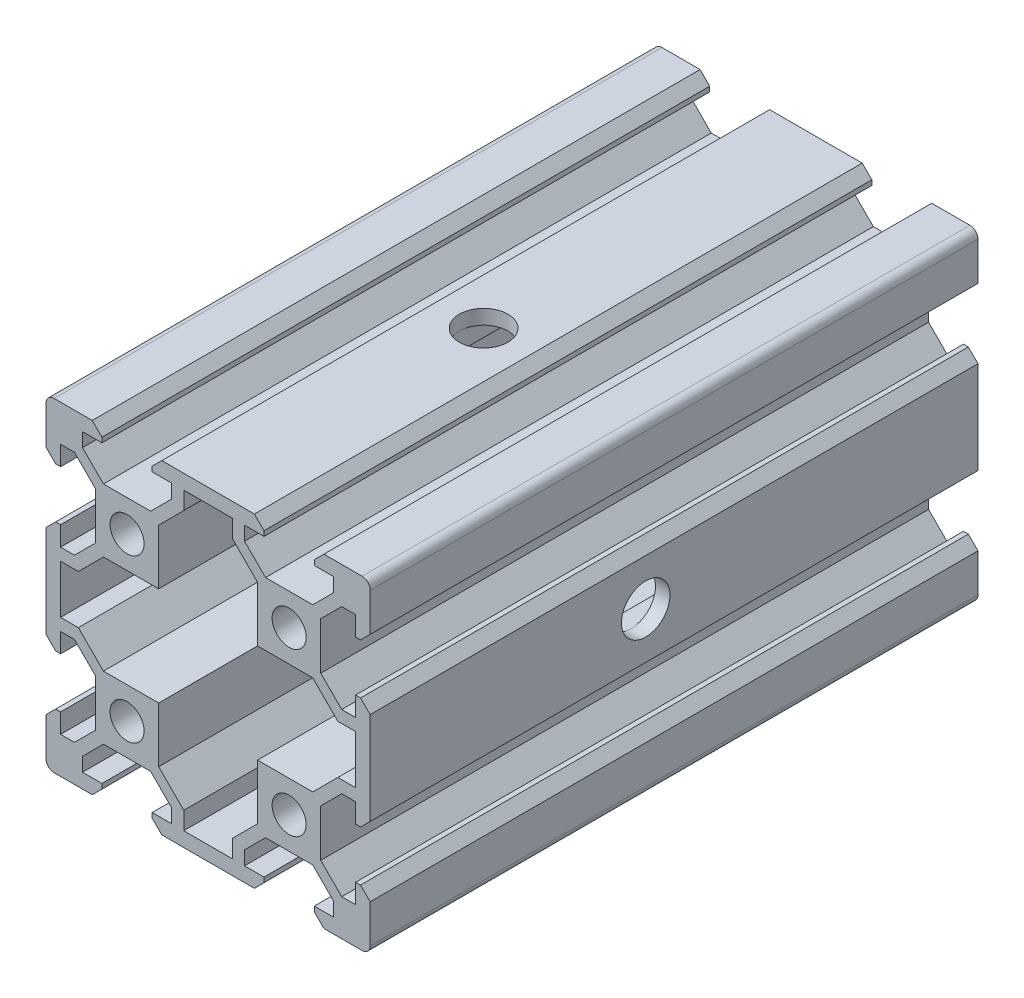
from build123d import *

# Parameters (mm, degrees)
SKETCH_1_R         = 2.1
EXTRUDE_1_DEPTH    = 75
VERRUNDUNG1_R      = 1
SKETCH1_R          = 3
CUT_EXTRUDE1_DEPTH = 41


with BuildPart() as part:
    # 草图1 → 凸台-拉伸1 (new body)
    with BuildSketch(Plane.XY):
        Polygon((5.71, 20), (-5.71, 20), (-6.9, 18.81), (-6.9, 18.2), (-4.5, 18.2), (-4.5, 16.489949494), (-7.089949494, 13.9), (-12.910050506, 13.9), (-15.5, 16.489949494), (-15.5, 18.2), (-13.1, 18.2), (-13.1, 18.81), (-14.29, 20), (-20, 20), (-20, 14.29), (-18.81, 13.1), (-18.2, 13.1), (-18.2, 15.5), (-16.489949494, 15.5), (-13.9, 12.910050506), (-13.9, 7.089949494), (-16.489949494, 4.5), (-18.2, 4.5), (-18.2, 6.9), (-18.81, 6.9), (-20, 5.71), (-20, -5.71), (-18.81, -6.9), (-18.2, -6.9), (-18.2, -4.5), (-16.489949494, -4.5), (-13.9, -7.089949494), (-13.9, -12.910050506), (-16.489949494, -15.5), (-18.2, -15.5), (-18.2, -13.1), (-18.81, -13.1), (-20, -14.29), (-20, -20), (-14.29, -20), (-13.1, -18.81), (-13.1, -18.2), (-15.5, -18.2), (-15.5, -16.489949494), (-12.910050506, -13.9), (-7.089949494, -13.9), (-4.5, -16.489949494), (-4.5, -18.2), (-6.9, -18.2), (-6.9, -18.81), (-5.71, -20), (5.71, -20), (6.9, -18.81), (6.9, -18.2), (4.5, -18.2), (4.5, -16.489949494), (7.089949494, -13.9), (12.910050506, -13.9), (15.5, -16.489949494), (15.5, -18.2), (13.1, -18.2), (13.1, -18.81), (14.29, -20), (20, -20), (20, -14.29), (18.81, -13.1), (18.2, -13.1), (18.2, -15.5), (16.489949494, -15.5), (13.9, -12.910050506), (13.9, -7.089949494), (16.489949494, -4.5), (18.2, -4.5), (18.2, -6.9), (18.81, -6.9), (20, -5.71), (20, 5.71), (18.81, 6.9), (18.2, 6.9), (18.2, 4.5), (16.489949494, 4.5), (13.9, 7.089949494), (13.9, 12.910050506), (16.489949494, 15.5), (18.2, 15.5), (18.2, 13.1), (18.81, 13.1), (20, 14.29), (20, 20), (14.29, 20), (13.1, 18.81), (13.1, 18.2), (15.5, 18.2), (15.5, 16.489949494), (12.910050506, 13.9), (7.089949494, 13.9), (4.5, 16.489949494), (4.5, 18.2), (6.9, 18.2), (6.9, 18.81), align=None)
        with Locations((-10, 10)):
            Circle(SKETCH_1_R, mode=Mode.SUBTRACT)
        with Locations((-10, -10)):
            Circle(SKETCH_1_R, mode=Mode.SUBTRACT)
        with Locations((10, -10)):
            Circle(SKETCH_1_R, mode=Mode.SUBTRACT)
        with Locations((10, 10)):
            Circle(SKETCH_1_R, mode=Mode.SUBTRACT)
        Polygon((-6.1, 6.1), (-6.1, 12.910050506), (-3, 16.010050506), (-3, 18.2), (3, 18.2), (3, 16.010050506), (6.1, 12.910050506), (6.1, 6.1), (12.910050506, 6.1), (16.010050506, 3), (18.2, 3), (18.2, -3), (16.010050506, -3), (12.910050506, -6.1), (6.1, -6.1), (6.1, -12.910050506), (3, -16.010050506), (3, -18.2), (-3, -18.2), (-3, -16.010050506), (-6.1, -12.910050506), (-6.1, -6.1), (-12.910050506, -6.1), (-16.010050506, -3), (-18.2, -3), (-18.2, 3), (-16.010050506, 3), (-12.910050506, 6.1), align=None, mode=Mode.SUBTRACT)
    extrude(amount=EXTRUDE_1_DEPTH)

    # Verrundung1
    verrundung1_edges = [part.edges().sort_by_distance(p)[0] for p in [
        (20, 20, 37.5),
        (20, -20, 37.5),
        (-20, -20, 37.5),
        (-20, 20, 37.5),
    ]]
    fillet(verrundung1_edges, radius=VERRUNDUNG1_R)

    # Sketch1 → Cut-Extrude1 (cut, through all)
    with BuildSketch(Plane.ZY.offset(20)):
        with Locations((41, 0)):
            Circle(SKETCH1_R)
    cut_extrude1 = extrude(amount=-CUT_EXTRUDE1_DEPTH, mode=Mode.SUBTRACT)

    # Mirror1: Cut-Extrude1 across plane
    add(cut_extrude1.mirror(Plane(origin=(0, 0, 0), x_dir=(0, 0, 1), z_dir=(-0.707106781, -0.707106781, 0))), mode=Mode.SUBTRACT)


solid = part.part
